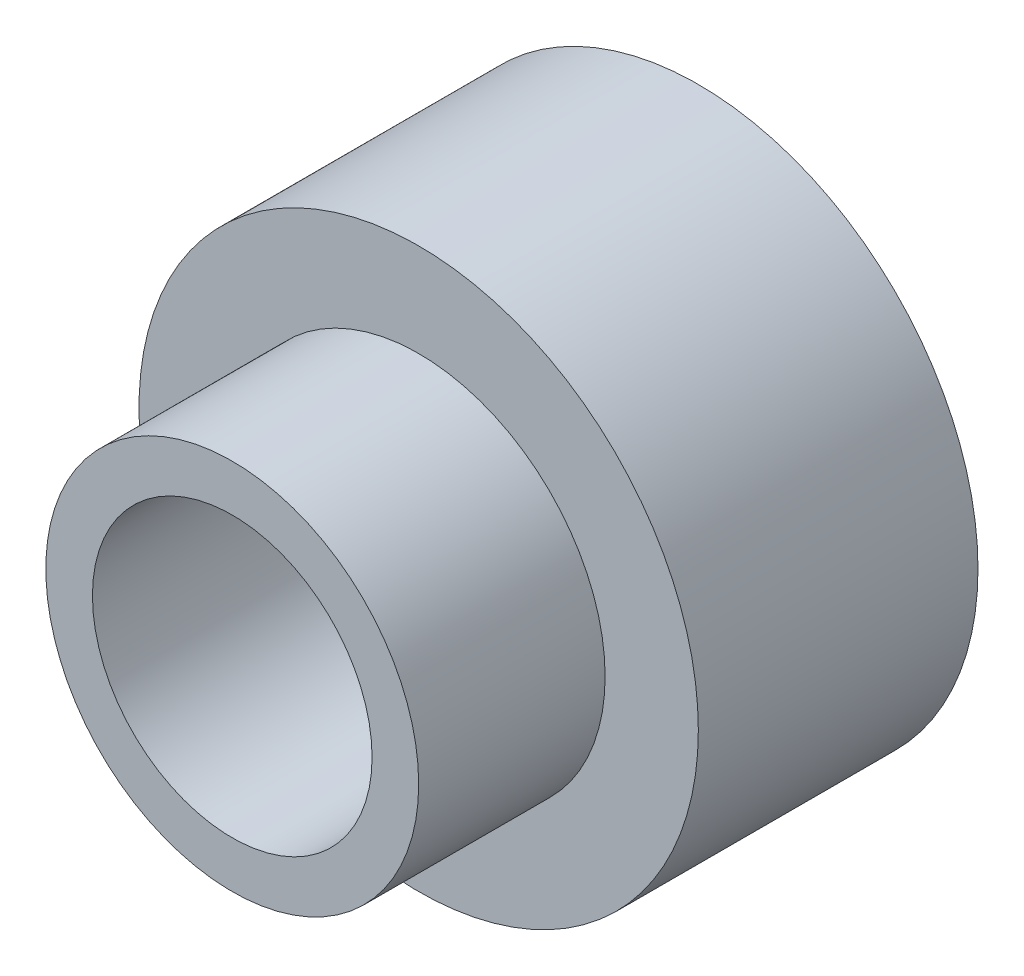
from build123d import *

# Parameters (mm, degrees)
SKETCH_1_R          = 3
EXTRUDE_1_DEPTH     = 3
SKETCH_1_3_R        = 2
EXTRUDE_2_DEPTH     = 5
SKETCH_1_4_R        = 1.5
CUT_EXTRUDE_1_DEPTH = 6


with BuildPart() as part:
    # Sketch 1 → Extrude 1 (new body)
    with BuildSketch(Plane.XY):
        Circle(SKETCH_1_R)
    extrude(amount=EXTRUDE_1_DEPTH)

    # Sketch 1_3 → Extrude 2 (add)
    with BuildSketch(Plane.XY):
        Circle(SKETCH_1_3_R)
    extrude(amount=EXTRUDE_2_DEPTH)

    # Sketch 1_4 → Cut-Extrude 1 (cut, through all)
    with BuildSketch(Plane.XY):
        Circle(SKETCH_1_4_R)
    extrude(amount=CUT_EXTRUDE_1_DEPTH, mode=Mode.SUBTRACT)


solid = part.part
